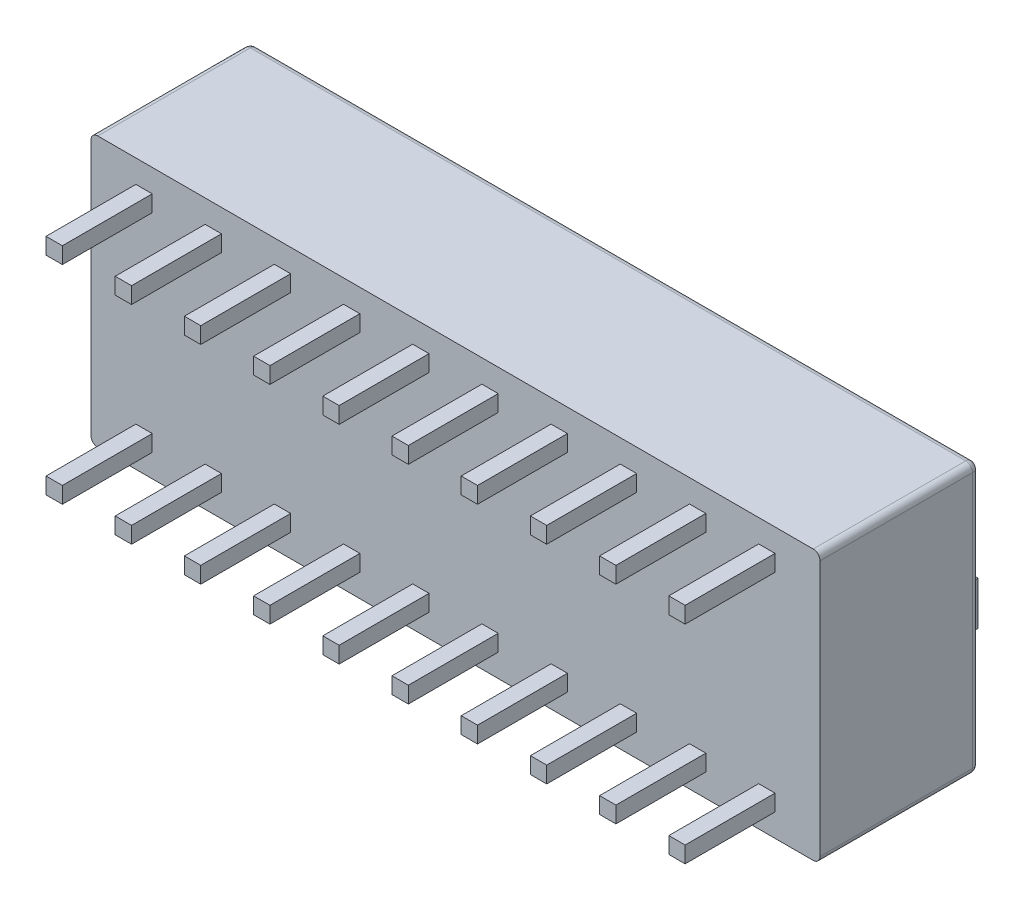
from build123d import *

# Parameters (mm, degrees)
IZIM1_W                        = 26.76
IZIM1_H                        = 9.9
Y_KSEKLIK_EKSTR_ZYON1_DEPTH    = 5.85
IZIM2_W                        = 1.4
IZIM2_H                        = 3.2
KES_EKSTR_ZYON1_DEPTH          = 1
IZIM3_W                        = 1.4
IZIM3_H                        = 1.6
Y_KSEKLIK_EKSTR_ZYON2_DEPTH    = 2.2
Y_KSEKLIK_EKSTR_ZYON2_2_DEPTH  = 2.2
Y_KSEKLIK_EKSTR_ZYON2_3_DEPTH  = 2.2
Y_KSEKLIK_EKSTR_ZYON2_4_DEPTH  = 2.2
Y_KSEKLIK_EKSTR_ZYON2_5_DEPTH  = 2.2
Y_KSEKLIK_EKSTR_ZYON2_6_DEPTH  = 2.2
Y_KSEKLIK_EKSTR_ZYON2_7_DEPTH  = 2.2
Y_KSEKLIK_EKSTR_ZYON2_8_DEPTH  = 2.2
Y_KSEKLIK_EKSTR_ZYON2_9_DEPTH  = 2.2
Y_KSEKLIK_EKSTR_ZYON2_10_DEPTH = 2.2
IZIM4_W                        = 1.4
IZIM4_H                        = 1.6
Y_KSEKLIK_EKSTR_ZYON3_DEPTH    = 0.9
Y_KSEKLIK_EKSTR_ZYON3_2_DEPTH  = 0.9
Y_KSEKLIK_EKSTR_ZYON3_3_DEPTH  = 0.9
Y_KSEKLIK_EKSTR_ZYON3_4_DEPTH  = 0.9
Y_KSEKLIK_EKSTR_ZYON3_5_DEPTH  = 0.9
Y_KSEKLIK_EKSTR_ZYON3_6_DEPTH  = 0.9
Y_KSEKLIK_EKSTR_ZYON3_7_DEPTH  = 0.9
Y_KSEKLIK_EKSTR_ZYON3_8_DEPTH  = 0.9
Y_KSEKLIK_EKSTR_ZYON3_9_DEPTH  = 0.9
Y_KSEKLIK_EKSTR_ZYON3_10_DEPTH = 0.9
RADYUS1_R                      = 0.25
IZIM5_W                        = 0.6
IZIM5_H                        = 0.6
Y_KSEKLIK_EKSTR_ZYON4_DEPTH    = 3.3


with BuildPart() as part:
    # Çizim1 → Yükseklik-Ekstrüzyon1 (new body)
    with BuildSketch(Plane.XY):
        Rectangle(IZIM1_W, IZIM1_H)
    extrude(amount=Y_KSEKLIK_EKSTR_ZYON1_DEPTH)

    # Çizim2 → Kes-Ekstrüzyon1 (cut)
    with BuildSketch(Plane(origin=(0, 0, 0), x_dir=(-1, 0, 0), z_dir=(0, 0, -1))):
        with Locations((-11.43, 0)):
            Rectangle(IZIM2_W, IZIM2_H)
        with Locations((-8.89, 0)):
            Rectangle(IZIM2_W, IZIM2_H)
        with Locations((-6.35, 0)):
            Rectangle(IZIM2_W, IZIM2_H)
        with Locations((-3.81, 0)):
            Rectangle(IZIM2_W, IZIM2_H)
        with Locations((-1.27, 0)):
            Rectangle(IZIM2_W, IZIM2_H)
        with Locations((1.27, 0)):
            Rectangle(IZIM2_W, IZIM2_H)
        with Locations((3.81, 0)):
            Rectangle(IZIM2_W, IZIM2_H)
        with Locations((6.35, 0)):
            Rectangle(IZIM2_W, IZIM2_H)
        with Locations((8.89, 0)):
            Rectangle(IZIM2_W, IZIM2_H)
        with Locations((11.43, 0)):
            Rectangle(IZIM2_W, IZIM2_H)
    extrude(amount=-KES_EKSTR_ZYON1_DEPTH, mode=Mode.SUBTRACT)

    # Radyus1
    radyus1_edges = [part.edges().sort_by_distance(p)[0] for p in [
        (0, -4.95, 0),
        (-13.38, 0, 0),
        (0, 4.95, 0),
        (13.38, 0, 0),
        (13.38, -4.95, 2.925),
        (-13.38, -4.95, 2.925),
        (-13.38, 4.95, 2.925),
        (13.38, 4.95, 2.925),
    ]]
    fillet(radyus1_edges, radius=RADYUS1_R)

    # Çizim5 → Yükseklik-Ekstrüzyon4 (add)
    with BuildSketch(Plane.XY.offset(5.85)):
        with Locations((11.43, -3.81)):
            Rectangle(IZIM5_W, IZIM5_H)
        with Locations((8.89, -3.81)):
            Rectangle(IZIM5_W, IZIM5_H)
        with Locations((6.35, -3.81)):
            Rectangle(IZIM5_W, IZIM5_H)
        with Locations((3.81, -3.81)):
            Rectangle(IZIM5_W, IZIM5_H)
        with Locations((1.27, -3.81)):
            Rectangle(IZIM5_W, IZIM5_H)
        with Locations((-1.27, -3.81)):
            Rectangle(IZIM5_W, IZIM5_H)
        with Locations((-3.81, -3.81)):
            Rectangle(IZIM5_W, IZIM5_H)
        with Locations((-6.35, -3.81)):
            Rectangle(IZIM5_W, IZIM5_H)
        with Locations((-8.89, -3.81)):
            Rectangle(IZIM5_W, IZIM5_H)
        with Locations((-11.43, -3.81)):
            Rectangle(IZIM5_W, IZIM5_H)
        with Locations((-11.43, 3.81)):
            Rectangle(IZIM5_W, IZIM5_H)
        with Locations((-8.89, 3.81)):
            Rectangle(IZIM5_W, IZIM5_H)
        with Locations((-6.35, 3.81)):
            Rectangle(IZIM5_W, IZIM5_H)
        with Locations((-3.81, 3.81)):
            Rectangle(IZIM5_W, IZIM5_H)
        with Locations((-1.27, 3.81)):
            Rectangle(IZIM5_W, IZIM5_H)
        with Locations((1.27, 3.81)):
            Rectangle(IZIM5_W, IZIM5_H)
        with Locations((3.81, 3.81)):
            Rectangle(IZIM5_W, IZIM5_H)
        with Locations((6.35, 3.81)):
            Rectangle(IZIM5_W, IZIM5_H)
        with Locations((8.89, 3.81)):
            Rectangle(IZIM5_W, IZIM5_H)
        with Locations((11.43, 3.81)):
            Rectangle(IZIM5_W, IZIM5_H)
    extrude(amount=Y_KSEKLIK_EKSTR_ZYON4_DEPTH)


with BuildPart() as body_2:
    # Çizim3 → Yükseklik-Ekstrüzyon2 (new body)
    with BuildSketch(Plane(origin=(0, 0, 1), x_dir=(-1, 0, 0), z_dir=(0, 0, -1))):
        with Locations((-11.43, -0.8)):
            Rectangle(IZIM3_W, IZIM3_H)
    extrude(amount=Y_KSEKLIK_EKSTR_ZYON2_DEPTH)


with BuildPart() as body_3:
    # Çizim3 → Y_kseklik-Ekstr_zyon2 2 (new body)
    with BuildSketch(Plane(origin=(0, 0, 1), x_dir=(-1, 0, 0), z_dir=(0, 0, -1))):
        with Locations((-8.89, -0.8)):
            Rectangle(IZIM3_W, IZIM3_H)
    extrude(amount=Y_KSEKLIK_EKSTR_ZYON2_2_DEPTH)


with BuildPart() as body_4:
    # Çizim3 → Y_kseklik-Ekstr_zyon2 3 (new body)
    with BuildSketch(Plane(origin=(0, 0, 1), x_dir=(-1, 0, 0), z_dir=(0, 0, -1))):
        with Locations((-6.35, -0.8)):
            Rectangle(IZIM3_W, IZIM3_H)
    extrude(amount=Y_KSEKLIK_EKSTR_ZYON2_3_DEPTH)


with BuildPart() as body_5:
    # Çizim3 → Y_kseklik-Ekstr_zyon2 4 (new body)
    with BuildSketch(Plane(origin=(0, 0, 1), x_dir=(-1, 0, 0), z_dir=(0, 0, -1))):
        with Locations((-3.81, -0.8)):
            Rectangle(IZIM3_W, IZIM3_H)
    extrude(amount=Y_KSEKLIK_EKSTR_ZYON2_4_DEPTH)


with BuildPart() as body_6:
    # Çizim3 → Y_kseklik-Ekstr_zyon2 5 (new body)
    with BuildSketch(Plane(origin=(0, 0, 1), x_dir=(-1, 0, 0), z_dir=(0, 0, -1))):
        with Locations((-1.27, -0.8)):
            Rectangle(IZIM3_W, IZIM3_H)
    extrude(amount=Y_KSEKLIK_EKSTR_ZYON2_5_DEPTH)


with BuildPart() as body_7:
    # Çizim3 → Y_kseklik-Ekstr_zyon2 6 (new body)
    with BuildSketch(Plane(origin=(0, 0, 1), x_dir=(-1, 0, 0), z_dir=(0, 0, -1))):
        with Locations((1.27, -0.8)):
            Rectangle(IZIM3_W, IZIM3_H)
    extrude(amount=Y_KSEKLIK_EKSTR_ZYON2_6_DEPTH)


with BuildPart() as body_8:
    # Çizim3 → Y_kseklik-Ekstr_zyon2 7 (new body)
    with BuildSketch(Plane(origin=(0, 0, 1), x_dir=(-1, 0, 0), z_dir=(0, 0, -1))):
        with Locations((3.81, -0.8)):
            Rectangle(IZIM3_W, IZIM3_H)
    extrude(amount=Y_KSEKLIK_EKSTR_ZYON2_7_DEPTH)


with BuildPart() as body_9:
    # Çizim3 → Y_kseklik-Ekstr_zyon2 8 (new body)
    with BuildSketch(Plane(origin=(0, 0, 1), x_dir=(-1, 0, 0), z_dir=(0, 0, -1))):
        with Locations((6.35, -0.8)):
            Rectangle(IZIM3_W, IZIM3_H)
    extrude(amount=Y_KSEKLIK_EKSTR_ZYON2_8_DEPTH)


with BuildPart() as body_10:
    # Çizim3 → Y_kseklik-Ekstr_zyon2 9 (new body)
    with BuildSketch(Plane(origin=(0, 0, 1), x_dir=(-1, 0, 0), z_dir=(0, 0, -1))):
        with Locations((8.89, -0.8)):
            Rectangle(IZIM3_W, IZIM3_H)
    extrude(amount=Y_KSEKLIK_EKSTR_ZYON2_9_DEPTH)


with BuildPart() as body_11:
    # Çizim3 → Y_kseklik-Ekstr_zyon2 10 (new body)
    with BuildSketch(Plane(origin=(0, 0, 1), x_dir=(-1, 0, 0), z_dir=(0, 0, -1))):
        with Locations((11.43, -0.8)):
            Rectangle(IZIM3_W, IZIM3_H)
    extrude(amount=Y_KSEKLIK_EKSTR_ZYON2_10_DEPTH)


with BuildPart() as body_12:
    # Çizim4 → Yükseklik-Ekstrüzyon3 (new body)
    with BuildSketch(Plane(origin=(0, 0, 1), x_dir=(-1, 0, 0), z_dir=(0, 0, -1))):
        with Locations((-11.43, 0.8)):
            Rectangle(IZIM4_W, IZIM4_H)
    extrude(amount=Y_KSEKLIK_EKSTR_ZYON3_DEPTH)


with BuildPart() as body_13:
    # Çizim4 → Y_kseklik-Ekstr_zyon3 2 (new body)
    with BuildSketch(Plane(origin=(0, 0, 1), x_dir=(-1, 0, 0), z_dir=(0, 0, -1))):
        with Locations((-8.89, 0.8)):
            Rectangle(IZIM4_W, IZIM4_H)
    extrude(amount=Y_KSEKLIK_EKSTR_ZYON3_2_DEPTH)


with BuildPart() as body_14:
    # Çizim4 → Y_kseklik-Ekstr_zyon3 3 (new body)
    with BuildSketch(Plane(origin=(0, 0, 1), x_dir=(-1, 0, 0), z_dir=(0, 0, -1))):
        with Locations((-6.35, 0.8)):
            Rectangle(IZIM4_W, IZIM4_H)
    extrude(amount=Y_KSEKLIK_EKSTR_ZYON3_3_DEPTH)


with BuildPart() as body_15:
    # Çizim4 → Y_kseklik-Ekstr_zyon3 4 (new body)
    with BuildSketch(Plane(origin=(0, 0, 1), x_dir=(-1, 0, 0), z_dir=(0, 0, -1))):
        with Locations((-3.81, 0.8)):
            Rectangle(IZIM4_W, IZIM4_H)
    extrude(amount=Y_KSEKLIK_EKSTR_ZYON3_4_DEPTH)


with BuildPart() as body_16:
    # Çizim4 → Y_kseklik-Ekstr_zyon3 5 (new body)
    with BuildSketch(Plane(origin=(0, 0, 1), x_dir=(-1, 0, 0), z_dir=(0, 0, -1))):
        with Locations((-1.27, 0.8)):
            Rectangle(IZIM4_W, IZIM4_H)
    extrude(amount=Y_KSEKLIK_EKSTR_ZYON3_5_DEPTH)


with BuildPart() as body_17:
    # Çizim4 → Y_kseklik-Ekstr_zyon3 6 (new body)
    with BuildSketch(Plane(origin=(0, 0, 1), x_dir=(-1, 0, 0), z_dir=(0, 0, -1))):
        with Locations((1.27, 0.8)):
            Rectangle(IZIM4_W, IZIM4_H)
    extrude(amount=Y_KSEKLIK_EKSTR_ZYON3_6_DEPTH)


with BuildPart() as body_18:
    # Çizim4 → Y_kseklik-Ekstr_zyon3 7 (new body)
    with BuildSketch(Plane(origin=(0, 0, 1), x_dir=(-1, 0, 0), z_dir=(0, 0, -1))):
        with Locations((3.81, 0.8)):
            Rectangle(IZIM4_W, IZIM4_H)
    extrude(amount=Y_KSEKLIK_EKSTR_ZYON3_7_DEPTH)


with BuildPart() as body_19:
    # Çizim4 → Y_kseklik-Ekstr_zyon3 8 (new body)
    with BuildSketch(Plane(origin=(0, 0, 1), x_dir=(-1, 0, 0), z_dir=(0, 0, -1))):
        with Locations((6.35, 0.8)):
            Rectangle(IZIM4_W, IZIM4_H)
    extrude(amount=Y_KSEKLIK_EKSTR_ZYON3_8_DEPTH)


with BuildPart() as body_20:
    # Çizim4 → Y_kseklik-Ekstr_zyon3 9 (new body)
    with BuildSketch(Plane(origin=(0, 0, 1), x_dir=(-1, 0, 0), z_dir=(0, 0, -1))):
        with Locations((8.89, 0.8)):
            Rectangle(IZIM4_W, IZIM4_H)
    extrude(amount=Y_KSEKLIK_EKSTR_ZYON3_9_DEPTH)


with BuildPart() as body_21:
    # Çizim4 → Y_kseklik-Ekstr_zyon3 10 (new body)
    with BuildSketch(Plane(origin=(0, 0, 1), x_dir=(-1, 0, 0), z_dir=(0, 0, -1))):
        with Locations((11.43, 0.8)):
            Rectangle(IZIM4_W, IZIM4_H)
    extrude(amount=Y_KSEKLIK_EKSTR_ZYON3_10_DEPTH)


solid = Compound([part.part, body_2.part, body_3.part, body_4.part, body_5.part, body_6.part, body_7.part, body_8.part, body_9.part, body_10.part, body_11.part, body_12.part, body_13.part, body_14.part, body_15.part, body_16.part, body_17.part, body_18.part, body_19.part, body_20.part, body_21.part])
